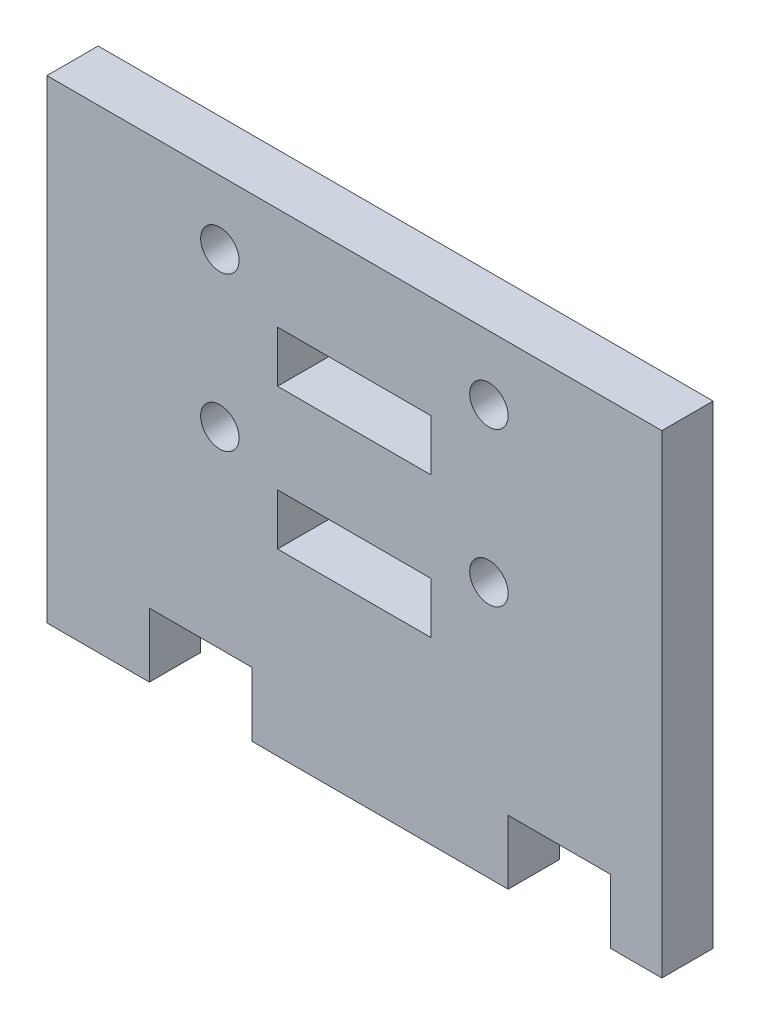
from build123d import *

# Parameters (mm, degrees)
SKETCH1_R           = 0.75
SKETCH1_W           = 6
SKETCH1_H           = 2
BOSS_EXTRUDE1_DEPTH = 2


with BuildPart() as part:
    # Sketch1 → Boss-Extrude1 (new body)
    with BuildSketch(Plane.XY):
        Polygon((5, 2), (9, 2), (9, -0.5), (19, -0.5), (19, 2), (23, 2), (23, -0.5), (25, -0.5), (25, 18), (1, 18), (1, -0.5), (5, -0.5), align=None)
        with Locations((7.75, 15.5)):
            Circle(SKETCH1_R, mode=Mode.SUBTRACT)
        with Locations((18.25, 15.5)):
            Circle(SKETCH1_R, mode=Mode.SUBTRACT)
        with Locations((18.25, 9.5)):
            Circle(SKETCH1_R, mode=Mode.SUBTRACT)
        with Locations((7.75, 9.5)):
            Circle(SKETCH1_R, mode=Mode.SUBTRACT)
        with Locations((13, 13)):
            Rectangle(SKETCH1_W, SKETCH1_H, mode=Mode.SUBTRACT)
        with Locations((13, 7.5)):
            Rectangle(SKETCH1_W, SKETCH1_H, mode=Mode.SUBTRACT)
    extrude(amount=BOSS_EXTRUDE1_DEPTH)


solid = part.part
